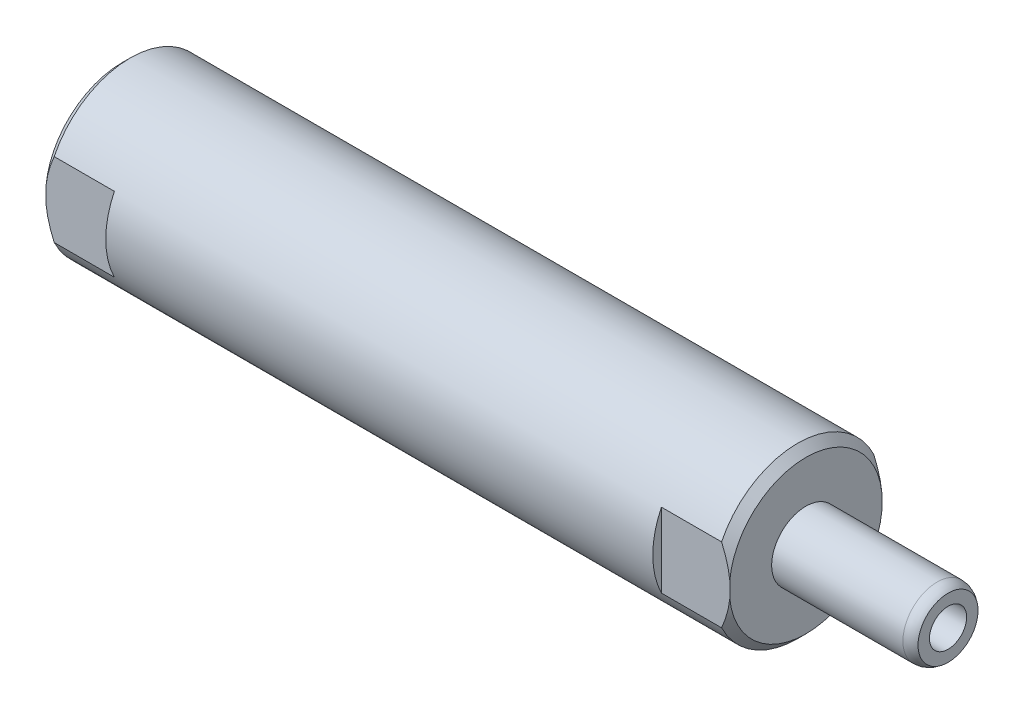
from build123d import *

# Parameters (mm, degrees)
CHAMFER1_SIZE           = 0.762
SKETCH5_W               = 6.35
SKETCH5_H               = 0.8001
CUT_EXTRUDE1_DEPTH      = 8.8613
CUT_EXTRUDE1_DEPTH_BACK = 8.8613
SKETCH6_W               = 6.35
SKETCH6_H               = 0.8001
CUT_EXTRUDE2_DEPTH      = 8.8613
CUT_EXTRUDE2_DEPTH_BACK = 8.8613


with BuildPart() as part:
    # Sketch1 → Revolve1 (revolve)
    with BuildSketch(Plane(origin=(0, 0, 0), x_dir=(-1, 0, 0), z_dir=(0, 0, -1)), mode=Mode.PRIVATE) as revolve1_sk:
        with BuildLine():
            Line((-76.708, 2.786922533), (-76.708, 0))
            Line((-76.708, 0), (0, 0))
            Line((0, 0), (0, 7.8613))
            Line((0, 7.8613), (-63.5, 7.8613))
            Line((-63.5, 7.8613), (-63.5, 3.175))
            Line((-63.5, 3.175), (-75.692, 3.175))
            ThreePointArc((-75.692, 3.175), (-76.235796865, 3.074678675), (-76.708, 2.786922533))
        make_face()
    revolve(revolve1_sk.sketch.rotate(Axis((76.708, 0, 0), (-1, 0, 0)), 270), axis=Axis((76.708, 0, 0), (-1, 0, 0)))  # turned: the seam where the file's is

    # Sketch2 → Cut-Revolve1 (revolve, cut)
    with BuildSketch(Plane(origin=(0, 0, 0), x_dir=(-1, 0, 0), z_dir=(0, 0, -1)), mode=Mode.PRIVATE) as cut_revolve1_sk:
        Polygon((-13.97, 4.9784), (-13.97, 0), (0, 0), (0, 6.1849), (-2.5527, 5.642306865), (-3.216606865, 4.9784), align=None)
    revolve(cut_revolve1_sk.sketch.rotate(Axis((13.97, 0, 0), (-1, 0, 0)), 270), axis=Axis((13.97, 0, 0), (-1, 0, 0)), mode=Mode.SUBTRACT)  # turned: the seam where the file's is

    # Sketch3 → Cut-Revolve2 (revolve, cut)
    with BuildSketch(Plane(origin=(0, 0, 0), x_dir=(-1, 0, 0), z_dir=(0, 0, -1)), mode=Mode.PRIVATE) as cut_revolve2_sk:
        Polygon((-76.708, 1.7272), (-76.708, 0), (-70.358, 0), (-71.395806461, 1.7272), align=None)
    revolve(cut_revolve2_sk.sketch.rotate(Axis((66.313858967, 0, 0), (-1, 0, 0)), 270), axis=Axis((66.313858967, 0, 0), (-1, 0, 0)), mode=Mode.SUBTRACT)  # turned: the seam where the file's is

    # Chamfer1
    chamfer1_edges = [part.edges().sort_by_distance(p)[0] for p in [
        (63.5, 0, -7.8613),
        (0, 0, -7.8613),
    ]]
    chamfer(chamfer1_edges, length=CHAMFER1_SIZE)

    # Sketch5 → Cut-Extrude1 (cut, two sides)
    with BuildSketch(Plane(origin=(0, 0, 0), x_dir=(1, 0, 0), z_dir=(0, 1, 0))) as cut_extrude1_sk:
        with Locations((3.175, 7.46125)):
            Rectangle(SKETCH5_W, SKETCH5_H)
        with Locations((3.175, -7.46125)):
            Rectangle(SKETCH5_W, SKETCH5_H)
    extrude(amount=CUT_EXTRUDE1_DEPTH, mode=Mode.SUBTRACT)
    extrude(cut_extrude1_sk.sketch, amount=-CUT_EXTRUDE1_DEPTH_BACK, mode=Mode.SUBTRACT)

    # Sketch6 → Cut-Extrude2 (cut, two sides)
    with BuildSketch(Plane(origin=(0, 0, 0), x_dir=(1, 0, 0), z_dir=(0, 1, 0))) as cut_extrude2_sk:
        with Locations((60.325, 7.46125)):
            Rectangle(SKETCH6_W, SKETCH6_H)
        with Locations((60.325, -7.46125)):
            Rectangle(SKETCH6_W, SKETCH6_H)
    extrude(amount=CUT_EXTRUDE2_DEPTH, mode=Mode.SUBTRACT)
    extrude(cut_extrude2_sk.sketch, amount=-CUT_EXTRUDE2_DEPTH_BACK, mode=Mode.SUBTRACT)


solid = part.part
